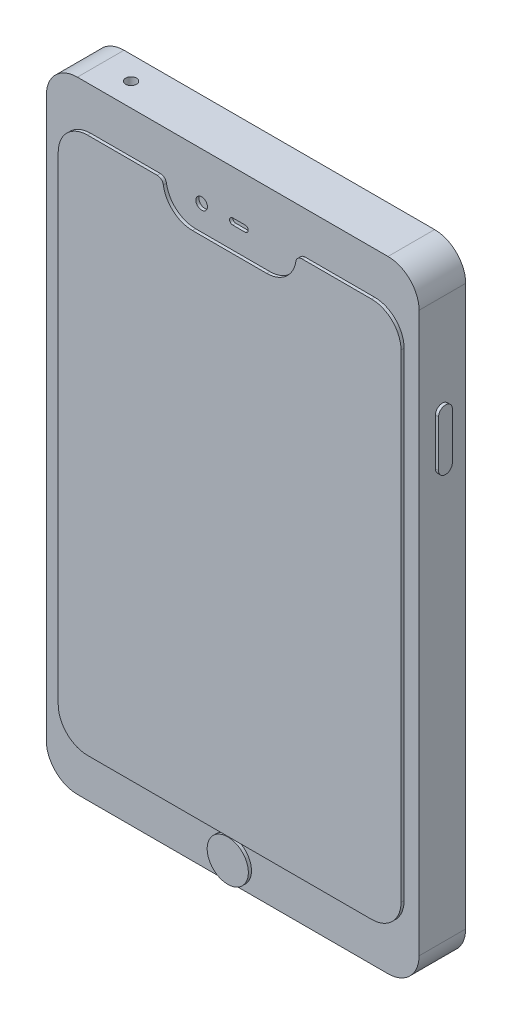
from build123d import *

# Parameters (mm, degrees)
BOSS_EXTRUDE1_DEPTH  = 15
BOSS_EXTRUDE2_DEPTH  = 16
CUT_EXTRUDE1_DEPTH   = 1
SKETCH6_R            = 6.626408405
BOSS_EXTRUDE7_DEPTH  = 16
CUT_EXTRUDE3_DEPTH   = 10
SKETCH8_R            = 1.860980047
CUT_EXTRUDE6_DEPTH   = 1
BOSS_EXTRUDE10_DEPTH = 1
SKETCH10_R           = 1
CUT_EXTRUDE7_DEPTH   = 7
SKETCH11_R           = 1.75
CUT_EXTRUDE8_DEPTH   = 20
BOSS_EXTRUDE13_DEPTH = 1
SKETCH13_R           = 6
SKETCH13_R_2         = 7.350371073
SKETCH13_R_3         = 5.24539952
SKETCH13_R_4         = 2.694037488
BOSS_EXTRUDE14_DEPTH = 1
BOSS_EXTRUDE19_DEPTH = 0.2


with BuildPart() as part:
    # Sketch3 → Boss-Extrude1 (new body)
    with BuildSketch(Plane.XY):
        with BuildLine():
            Line((-50, 100), (50, 100))
            ThreePointArc((50, 100), (57.071067812, 97.071067812), (60, 90))
            Line((60, 90), (60, -90))
            ThreePointArc((60, -90), (57.071067812, -97.071067812), (50, -100))
            Line((50, -100), (-50, -100))
            ThreePointArc((-50, -100), (-57.071067812, -97.071067812), (-60, -90))
            Line((-60, -90), (-60, 90))
            ThreePointArc((-60, 90), (-57.071067812, 97.071067812), (-50, 100))
        make_face()
    extrude(amount=BOSS_EXTRUDE1_DEPTH)

    # Sketch4 → Boss-Extrude2 (add)
    with BuildSketch(Plane.XY):
        with BuildLine():
            Line((-45.696681728, 86.479793583), (45.696681728, 86.479793583))
            ThreePointArc((45.696681728, 86.479793583), (52.400974756, 83.702784485), (55.177983854, 76.998491457))
            Line((55.177983854, 76.998491457), (55.177983854, -76.998491457))
            ThreePointArc((55.177983854, -76.998491457), (52.400974756, -83.702784485), (45.696681728, -86.479793583))
            Line((45.696681728, -86.479793583), (-45.696681728, -86.479793583))
            ThreePointArc((-45.696681728, -86.479793583), (-52.400974756, -83.702784485), (-55.177983854, -76.998491457))
            Line((-55.177983854, -76.998491457), (-55.177983854, 76.998491457))
            ThreePointArc((-55.177983854, 76.998491457), (-52.400974756, 83.702784485), (-45.696681728, 86.479793583))
        make_face()
    extrude(amount=BOSS_EXTRUDE2_DEPTH)

    # Sketch5 → Cut-Extrude1 (cut)
    with BuildSketch(Plane.XY.offset(16)):
        with BuildLine():
            Line((-11.964009061, 76.758679218), (11.964009061, 76.758679218))
            ThreePointArc((11.964009061, 76.758679218), (18.133018595, 79.040091667), (21.333225963, 84.786411725))
            ThreePointArc((21.333225963, 84.786411725), (22.008282474, 85.998549041), (23.309582539, 86.479793583))
            Line((23.309582539, 86.479793583), (-7.969065225, 86.479793583))
            Line((-7.969065225, 86.479793583), (-23.309582539, 86.479793583))
            ThreePointArc((-23.309582539, 86.479793583), (-22.008282474, 85.998549041), (-21.333225963, 84.786411725))
            ThreePointArc((-21.333225963, 84.786411725), (-18.133018595, 79.040091667), (-11.964009061, 76.758679218))
        make_face()
    extrude(amount=-CUT_EXTRUDE1_DEPTH, mode=Mode.SUBTRACT)

    # Sketch6 → Boss-Extrude7 (add)
    with BuildSketch(Plane.XY):
        with Locations((-0.588195402, -93.239793583)):
            Circle(SKETCH6_R)
    extrude(amount=BOSS_EXTRUDE7_DEPTH)

    # Sketch7 → Cut-Extrude3 (cut)
    with BuildSketch(Plane.XZ.offset(100)):
        with BuildLine():
            Line((3.684816301, 6.392233542), (-2.315183699, 6.392233542))
            ThreePointArc((-2.315183699, 6.392233542), (-3.422950157, 7.5), (-2.315183699, 8.607766458))
            Line((-2.315183699, 8.607766458), (3.684816301, 8.607766458))
            ThreePointArc((3.684816301, 8.607766458), (4.792582759, 7.5), (3.684816301, 6.392233542))
        make_face()
    extrude(amount=-CUT_EXTRUDE3_DEPTH, mode=Mode.SUBTRACT)

    # Sketch8 → Cut-Extrude6 (cut)
    with BuildSketch(Plane.XY.offset(15)):
        with Locations((-10, 84.758679218)):
            Circle(SKETCH8_R)
        with BuildLine():
            Line((0, 85.758679218), (4, 85.758679218))
            ThreePointArc((4, 85.758679218), (5, 84.758679218), (4, 83.758679218))
            Line((4, 83.758679218), (0, 83.758679218))
            ThreePointArc((0, 83.758679218), (-1, 84.758679218), (0, 85.758679218))
        make_face()
    extrude(amount=-CUT_EXTRUDE6_DEPTH, mode=Mode.SUBTRACT)

    # Sketch9 → Boss-Extrude10 (add)
    with BuildSketch(Plane(origin=(60, 0, 0), x_dir=(0, 0, -1), z_dir=(1, 0, 0))):
        with BuildLine():
            Line((-5.280651792, 58.138580799), (-5.280651792, 43.138580799))
            ThreePointArc((-5.280651792, 43.138580799), (-7.5, 40.919232591), (-9.719348208, 43.138580799))
            Line((-9.719348208, 43.138580799), (-9.719348208, 58.138580799))
            ThreePointArc((-9.719348208, 58.138580799), (-7.5, 60.357929008), (-5.280651792, 58.138580799))
        make_face()
    extrude(amount=BOSS_EXTRUDE10_DEPTH)

    # Sketch10 → Cut-Extrude7 (cut)
    with BuildSketch(Plane.XZ.offset(100)):
        with Locations((-38.926720921, 7.5)):
            Circle(SKETCH10_R)
    extrude(amount=-CUT_EXTRUDE7_DEPTH, mode=Mode.SUBTRACT)

    # Sketch11 → Cut-Extrude8 (cut)
    with BuildSketch(Plane(origin=(0, 100, 0), x_dir=(1, 0, 0), z_dir=(0, 1, 0))):
        with Locations((-40.22365253, -7.5)):
            Circle(SKETCH11_R)
    extrude(amount=-CUT_EXTRUDE8_DEPTH, mode=Mode.SUBTRACT)

    # Sketch12 → Boss-Extrude13 (add)
    with BuildSketch(Plane(origin=(0, 0, 0), x_dir=(-1, 0, 0), z_dir=(0, 0, -1))):
        with BuildLine():
            Line((-18.925763354, 91.964241382), (-52.203053416, 91.964241382))
            ThreePointArc((-52.203053416, 91.964241382), (-55.738587322, 90.499775288), (-57.203053416, 86.964241382))
            Line((-57.203053416, 86.964241382), (-57.203053416, 52.022440164))
            ThreePointArc((-57.203053416, 52.022440164), (-55.738587322, 48.486906258), (-52.203053416, 47.022440164))
            Line((-52.203053416, 47.022440164), (-18.925763354, 47.022440164))
            ThreePointArc((-18.925763354, 47.022440164), (-15.390229448, 48.486906258), (-13.925763354, 52.022440164))
            Line((-13.925763354, 52.022440164), (-13.925763354, 86.964241382))
            ThreePointArc((-13.925763354, 86.964241382), (-15.390229448, 90.499775288), (-18.925763354, 91.964241382))
        make_face()
    extrude(amount=BOSS_EXTRUDE13_DEPTH)

    # Sketch13 → Boss-Extrude14 (add)
    with BuildSketch(Plane(origin=(0, 0, -1), x_dir=(-1, 0, 0), z_dir=(0, 0, -1))):
        with Locations((-48.871309333, 80.649061989)):
            Circle(SKETCH13_R)
        with Locations((-48.871309333, 55.649061989)):
            Circle(SKETCH13_R_2)
        with Locations((-28.684304458, 66.649061989)):
            Circle(SKETCH13_R_3)
        with Locations((-28.684304458, 80.649061989)):
            Circle(SKETCH13_R_4)
    extrude(amount=BOSS_EXTRUDE14_DEPTH)

    # Sketch14 → Boss-Extrude19 (add)
    with BuildSketch(Plane(origin=(0, 0, 0), x_dir=(-1, 0, 0), z_dir=(0, 0, -1))):
        with BuildLine():
            add(Edge.make_bspline(
                [(-3.674445913, 33.570119731), (-6.586996245, 36.726182993), (-9.97051323, 37.977315522), (-13.231414187, 37.431600611)],
                knots=[0.231070837, 0.231070837, 0.231070837, 0.231070837, 0.765352683, 0.765352683, 0.765352683, 0.765352683], degree=3))
            ThreePointArc((-13.231414187, 37.431600611), (-15.343951329, 36.616365238), (-17.406574019, 35.68201545))
            ThreePointArc((-17.406574019, 35.68201545), (-39.698794696, -0.448046182), (-16.596818278, -36.065782519))
            ThreePointArc((-16.596818278, -36.065782519), (-12.966582836, -36.280567352), (-10.151005098, -33.978988787))
            ThreePointArc((-10.151005098, -33.978988787), (0, -29.774304804), (10.151005098, -33.978988787))
            ThreePointArc((10.151005098, -33.978988787), (12.966582836, -36.280567352), (16.596818278, -36.065782519))
            ThreePointArc((16.596818278, -36.065782519), (18.986564068, -34.866967613), (21.29020582, -33.510031062))
            ThreePointArc((21.29020582, -33.510031062), (30.111316996, -25.874768297), (36.332224295, -16.005140531))
            ThreePointArc((36.332224295, -16.005140531), (20.757436471, 1.37873001), (33.896238409, 20.669786341))
            ThreePointArc((33.896238409, 20.669786341), (26.727072351, 29.357429199), (17.406574019, 35.68201545))
            ThreePointArc((17.406574019, 35.68201545), (15.343951329, 36.616365238), (13.231414187, 37.431600611))
            add(Edge.make_bspline(
                [(3.674445913, 33.570119731), (6.586996245, 36.726182993), (9.97051323, 37.977315522), (13.231414187, 37.431600611)],
                knots=[0.231070837, 0.231070837, 0.231070837, 0.231070837, 0.765352683, 0.765352683, 0.765352683, 0.765352683], degree=3))
            ThreePointArc((3.674445913, 33.570119731), (0, 31.961055772), (-3.674445913, 33.570119731))
        make_face()
        with BuildLine():
            ThreePointArc((13.231414187, 59.583781152), (11.301026929, 45.532102859), (0, 36.961055772))
            ThreePointArc((0, 36.961055772), (1.930387259, 51.012734065), (13.231414187, 59.583781152))
        make_face()
    extrude(amount=BOSS_EXTRUDE19_DEPTH)


solid = part.part
